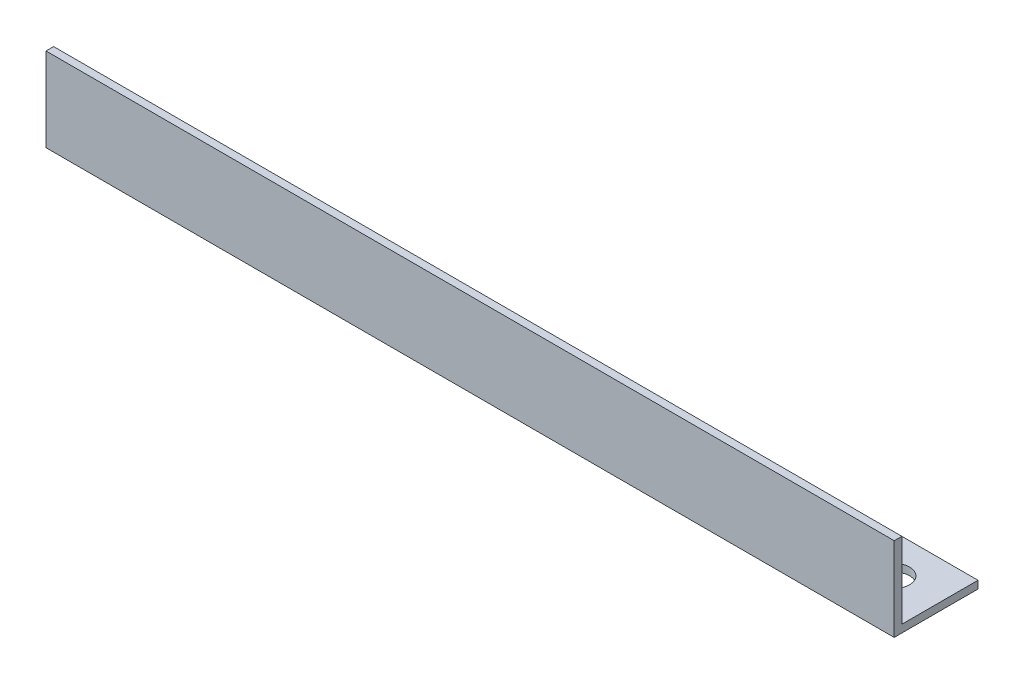
from build123d import *

# Parameters (mm, degrees)
EXTRUDE_1_DEPTH     = 334
SKETCH_2_R          = 6.05
CUT_EXTRUDE_1_DEPTH = 34


with BuildPart() as part:
    # Эскиз1 → Вытянуть-Тонкостенный1 (new body)
    with BuildSketch(Plane(origin=(0, 0, 0), x_dir=(0, 0, -1), z_dir=(1, 0, 0))):
        Polygon((0, 33), (0, 0), (33, 0), (33, 3), (3, 3), (3, 33), align=None)
    extrude(amount=EXTRUDE_1_DEPTH)

    # Эскиз2 → Вырез-Вытянуть1 (cut, through all)
    with BuildSketch(Plane.XZ):
        with Locations((316, -18)):
            Circle(SKETCH_2_R)
        with Locations((18, -18)):
            Circle(SKETCH_2_R)
    extrude(amount=-CUT_EXTRUDE_1_DEPTH, mode=Mode.SUBTRACT)


solid = part.part
